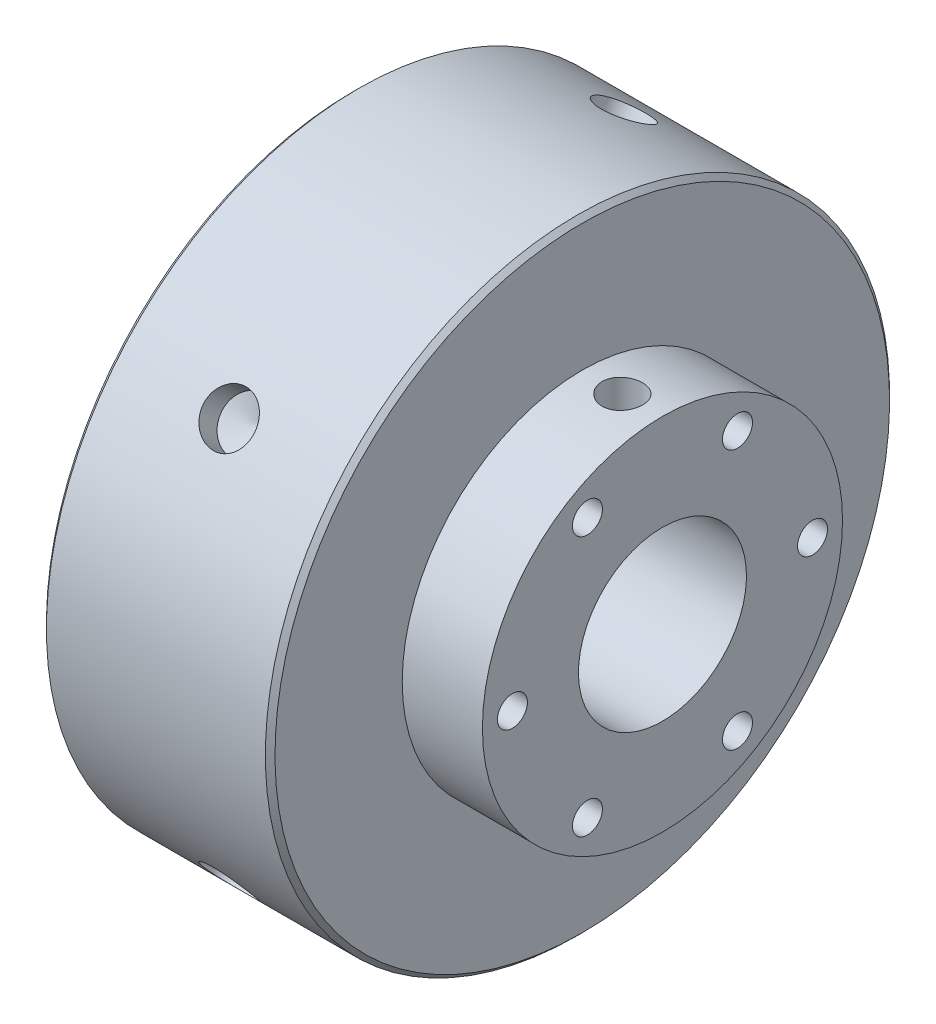
from build123d import *

# Parameters (mm, degrees)
SKETCH2_R                = 22.225
BORE_DEPTH               = 156.599620501
FACE_MOUNT_SCREWS_D      = 7.9375
SKETCH5_W                = 5.35813
SKETCH5_H                = 82.55
SET_SCREWS_AT_2_COUNT    = 2
SET_SCREWS_AT_2_PITCH    = 81.661
CHAMFER1_SIZE            = 1.27
SKETCH15_R               = 4
BOSS_EXTRUDE1_DEPTH      = 1
BOSS_EXTRUDE1_DEPTH_BACK = 40.64
SKETCH16_R               = 6.5
BOSS_EXTRUDE2_DEPTH      = 8
CHAMFER2_SIZE            = 0.381
CUT_EXTRUDE2_DEPTH       = 2
LPATTERN2_COUNT          = 2
LPATTERN2_PITCH          = 16.602964
LPATTERN2_2_COUNT        = 2
LPATTERN2_2_PITCH        = 16.602964
SKETCH18_R               = 47.625
SKETCH18_R_2             = 22.225
CUT_EXTRUDE3_DEPTH       = 0.0635
CIRPATTERN1_COUNT        = 4
CIRPATTERN1_ANGLE        = 240


with BuildPart() as part:
    # Sketch1 → Hub (revolve)
    with BuildSketch(Plane.XY, mode=Mode.PRIVATE) as hub_sk:
        Polygon((-30.226, 82.55), (30.226, 82.55), (30.226, 47.625), (51.435, 47.625), (51.435, 0), (-51.435, 0), (-51.435, 47.625), (-30.226, 47.625), align=None)
    revolve(hub_sk.sketch.rotate(Axis((-51.435, 0, 0), (1, 0, 0)), 180), axis=Axis((-51.435, 0, 0), (1, 0, 0)))

    # Sketch2 → Bore (cut, through all)
    with BuildSketch(Plane(origin=(51.435, 0, 0), x_dir=(0, 0, -1), z_dir=(1, 0, 0))):
        with Locations(Location((0, 0, 0), (0, 0, 90))):
            Circle(SKETCH2_R)
    extrude(amount=-BORE_DEPTH, mode=Mode.SUBTRACT)

    # Face Mount Screws (through all)
    with Locations(Plane(origin=(51.435, 0, 0), x_dir=(0, 0, -1), z_dir=(1, 0, 0))):
        with Locations((-39.6875, 0), (19.84375, 34.370383213), (19.84375, -34.370383213), (-19.84375, -34.370383213), (39.6875, 0), (-19.84375, 34.370383213)):
            Hole(FACE_MOUNT_SCREWS_D / 2)

    # Sketch5 → Set Screws (revolve, cut)
    with BuildSketch(Plane(origin=(-40.8305, 0, 0), x_dir=(0, 0, -1), z_dir=(1, 0, 0))):
        with Locations((2.679065, 41.275)):
            Rectangle(SKETCH5_W, SKETCH5_H)
    set_screws = revolve(axis=Axis((-40.8305, -6.35, 0), (0, 1, 0)), mode=Mode.SUBTRACT)

    # Set Screws at 2: Set Screws ×2
    with Locations(*[(i * SET_SCREWS_AT_2_PITCH, 0, 0) for i in range(1, SET_SCREWS_AT_2_COUNT)]):
        add(set_screws, mode=Mode.SUBTRACT)

    # Chamfer1
    chamfer1_edges = [part.edges().sort_by_distance(p)[0] for p in [
        (-30.226, 82.55, 0),
        (30.226, 82.55, 0),
    ]]
    chamfer(chamfer1_edges, length=CHAMFER1_SIZE)

    # Sketch12 → Cut-Revolve1 (revolve, cut)
    with BuildSketch(Plane.XY.offset(-73.66), mode=Mode.PRIVATE) as cut_revolve1_sk:
        Polygon((-7, 82.55), (-7, 12.54), (-4.25, 12.54), (-4.25, -82.55), (0, -82.55), (0, 82.55), align=None)
    revolve(cut_revolve1_sk.sketch.rotate(Axis((0, -82.55, -73.66), (0, 1, 0)), 180), axis=Axis((0, -82.55, -73.66), (0, 1, 0)), mode=Mode.SUBTRACT)

    # Sketch14 → Cut-Revolve2 (revolve, cut)
    with BuildSketch(Plane.XY.offset(-73.66)):
        Polygon((-16.603, -82.55), (-23.603, -82.55), (-23.603, -12.54), (-20.853, -12.54), (-20.853, 82.55), (-16.603, 82.55), align=None)
    cut_revolve2 = revolve(axis=Axis((-16.603, 82.55, -73.66), (0, -1, 0)), mode=Mode.SUBTRACT)

    # Mirror2: Cut-Revolve2 across plane
    add(cut_revolve2.mirror(Plane(origin=(0, 0, 0), x_dir=(0, 0, 1), z_dir=(1, 0, 0))), mode=Mode.SUBTRACT)

    # Sketch18 → Cut-Extrude3 (cut, symmetric)
    with BuildSketch(Plane(origin=(0, 0, 0), x_dir=(0, 0, -1), z_dir=(1, 0, 0))):
        with Locations(Location((0, 0, 0), (0, 0, 270))):
            Circle(SKETCH18_R)
        with Locations(Location((0, 0, 0), (0, 0, 90))):
            Circle(SKETCH18_R_2, mode=Mode.SUBTRACT)
    extrude(amount=CUT_EXTRUDE3_DEPTH, both=True, mode=Mode.SUBTRACT)

    # Sketch19 → 17_32 _0.53125_ Diameter Hole1 (revolve, cut)
    with BuildSketch(Plane(origin=(0, -71.490397082, -41.275), x_dir=(0, 0.499999999999998, -0.8660254037844399), z_dir=(1, 0, 0))):
        Polygon((0, 0), (0, 10.394392827), (6.731, 6.35), (6.731, 0), align=None)
    f_17_32_0_53125_diameter_hole1 = revolve(axis=Axis((0, -76.989658396, -44.45), (0, 0.8660254037844398, 0.49999999999999795)), mode=Mode.SUBTRACT)

    # CirPattern1: 17_32 _0.53125_ Diameter Hole1 ×4 about axis
    cirpattern1_axis = Axis((-51.435, 0, 0), (-1, 0, 0))
    for i in range(1, CIRPATTERN1_COUNT):
        add(f_17_32_0_53125_diameter_hole1.rotate(cirpattern1_axis, i * CIRPATTERN1_ANGLE / (CIRPATTERN1_COUNT - 1)), mode=Mode.SUBTRACT)


with BuildPart() as body_2:
    # Sketch15 → Boss-Extrude1 (new, two sides)
    with BuildSketch(Plane(origin=(0, 12.54, 0), x_dir=(1, 0, 0), z_dir=(0, 1, 0))) as boss_extrude1_sk:
        with Locations(Location((0, 73.66, 0), (0, 0, 180))):
            Circle(SKETCH15_R)
    extrude(amount=BOSS_EXTRUDE1_DEPTH)
    extrude(boss_extrude1_sk.sketch, amount=-BOSS_EXTRUDE1_DEPTH_BACK)

    # Sketch16 → Boss-Extrude2 (add)
    with BuildSketch(Plane(origin=(0, 13.54, 0), x_dir=(1, 0, 0), z_dir=(0, 1, 0))):
        with Locations(Location((0, 73.66, 0), (0, 0, 180))):
            Circle(SKETCH16_R)
    extrude(amount=BOSS_EXTRUDE2_DEPTH)

    # Chamfer2
    chamfer2_edges = [body_2.edges().sort_by_distance(p)[0] for p in [
        (4, -28.1, -73.66),
        (6.5, 21.54, -73.66),
    ]]
    chamfer(chamfer2_edges, length=CHAMFER2_SIZE)

    # Sketch17 → Cut-Extrude2 (cut)
    with BuildSketch(Plane(origin=(0, 21.54, 0), x_dir=(1, 0, 0), z_dir=(0, 1, 0))):
        Polygon((1.732050808, 76.66), (-1.732050808, 76.66), (-3.464101615, 73.66), (-1.732050808, 70.66), (1.732050808, 70.66), (3.464101615, 73.66), align=None)
    extrude(amount=-CUT_EXTRUDE2_DEPTH, mode=Mode.SUBTRACT)


with BuildPart() as lpattern2_1:
    # LPattern2: pattern copy
    add(body_2.part.moved(Location(Vector(1, 0, 0) * (1 * LPATTERN2_PITCH))))


with BuildPart() as lpattern2_2_1:
    # LPattern2 2: pattern copy
    add(body_2.part.moved(Location(Vector(-1, 0, 0) * (1 * LPATTERN2_2_PITCH))))


with BuildPart() as body_5:
    # Mirror4: mirrored copy
    add(lpattern2_1.part.mirror(Plane.ZX))


with BuildPart() as body_6:
    # Mirror4 2: mirrored copy
    add(lpattern2_2_1.part.mirror(Plane.ZX))


solid = Compound([part.part, body_2.part, body_5.part, body_6.part])
